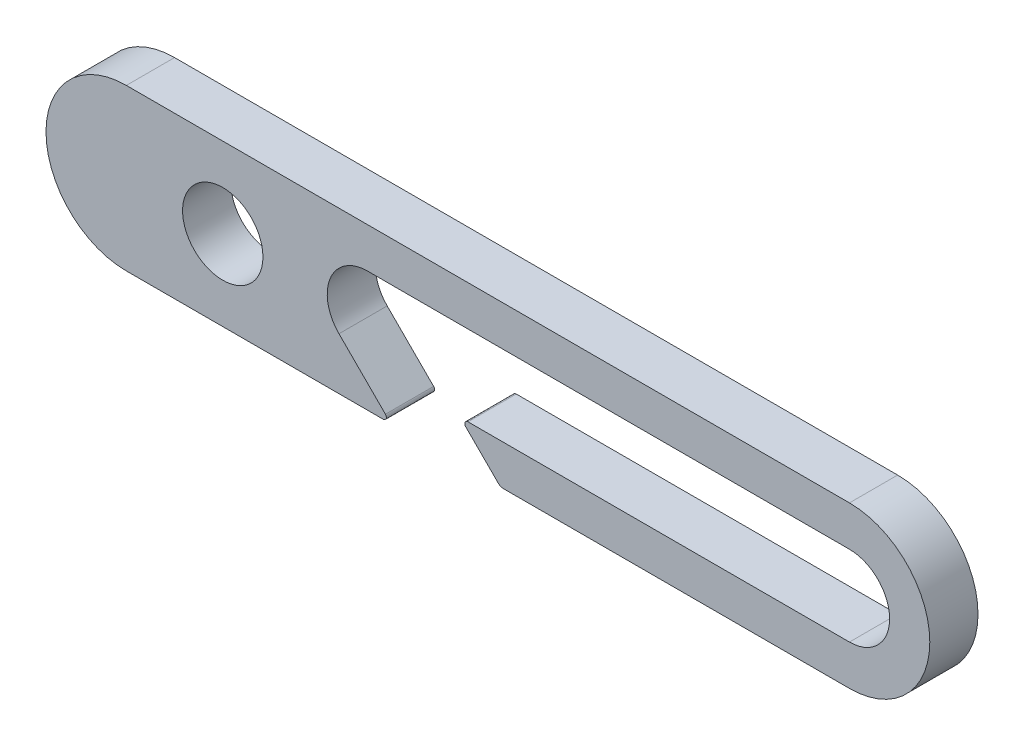
from build123d import *

# Parameters (mm, degrees)
SKETCH2_R           = 2.5
BOSS_EXTRUDE1_DEPTH = 3


with BuildPart() as part:
    # Sketch2 → Boss-Extrude1 (new body)
    with BuildSketch(Plane.XY):
        with BuildLine():
            Line((16.770370099, 3.355657737), (46.770370099, 3.355657737))
            ThreePointArc((46.770370099, 3.355657737), (49.270370099, 0.855657737), (46.770370099, -1.644342263))
            Line((46.770370099, -1.644342263), (23.033866759, -1.644342263))
            ThreePointArc((23.033866759, -1.644342263), (22.849090853, -1.767805576), (22.892445403, -1.985763619))
            Line((22.892445403, -1.985763619), (24.904577438, -3.997895654))
            ThreePointArc((24.904577438, -3.997895654), (25.066789112, -4.106282029), (25.258130828, -4.144342263))
            Line((25.258130828, -4.144342263), (46.770370099, -4.144342263))
            ThreePointArc((46.770370099, -4.144342263), (51.770370099, 0.855657737), (46.770370099, 5.855657737))
            Line((46.770370099, 5.855657737), (1.770370099, 5.855657737))
            ThreePointArc((1.770370099, 5.855657737), (-3.229629901, 0.855657737), (1.770370099, -4.144342263))
            Line((1.770370099, -4.144342263), (17.75199348, -4.144342263))
            ThreePointArc((17.75199348, -4.144342263), (17.936769387, -4.020878949), (17.893414837, -3.802920907))
            Line((17.893414837, -3.802920907), (15.002603146, -0.912109216))
            ThreePointArc((15.002603146, -0.912109216), (14.460671268, 1.812366318), (16.770370099, 3.355657737))
        make_face()
        with Locations((7.770370099, 0.855657737)):
            Circle(SKETCH2_R, mode=Mode.SUBTRACT)
    extrude(amount=BOSS_EXTRUDE1_DEPTH)


solid = part.part
